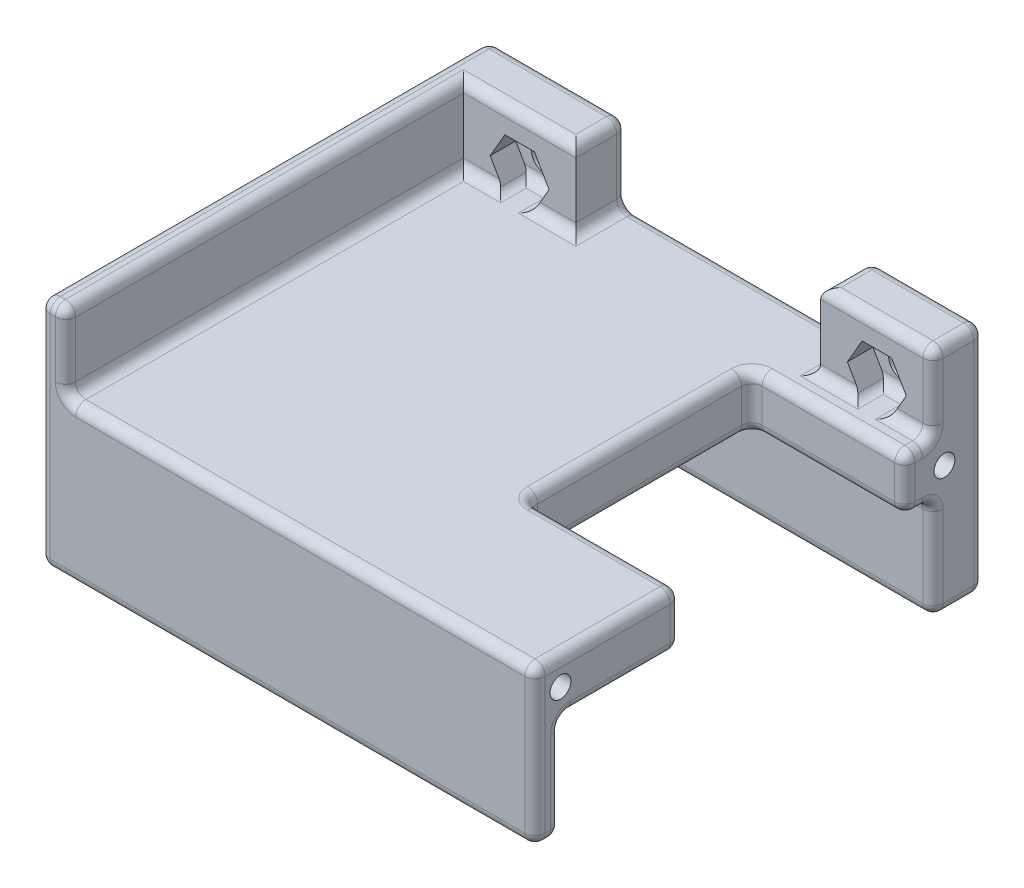
from build123d import *

# Parameters (mm, degrees)
BOSS_EXTRUDE1_DEPTH          = 5
CUT_EXTRUDE4_START           = 5
CUT_EXTRUDE4_DEPTH           = 2.5
BOSS_EXTRUDE2_DEPTH          = 41.5
BOSS_EXTRUDE3_START          = 41.5
SKETCH16_6_W                 = 46
SKETCH16_6_H                 = 10
BOSS_EXTRUDE3_DEPTH          = 2.5
SKETCH17_W                   = 15
SKETCH17_H                   = 22
CUT_EXTRUDE5_DEPTH           = 16.3
M2_5X0_45_TAPPED_HOLE2_D     = 2.05
M2_5X0_45_TAPPED_HOLE2_DEPTH = 15
M2_5X0_45_TAPPED_HOLE2_TIP   = 0.615882135
FILLET1_R                    = 1
M2_5_CLEARANCE_HOLE1_D       = 2.7


with BuildPart() as part:
    # Sketch16 → Boss-Extrude1 (new body)
    with BuildSketch(Plane.XY):
        Polygon((-12, -2.5), (-12, 5), (-25.5, 5), (-25.5, -17.8), (23, -17.8), (23, 5), (12, 5), (12, -2.5), align=None)
    extrude(amount=BOSS_EXTRUDE1_DEPTH)

    # Sketch16_5 → Cut-Extrude4 (cut)
    with BuildSketch(Plane.XY.offset(CUT_EXTRUDE4_START)):
        Polygon((-16.056624327, -2.5), (-14.613248654, 0), (-16.056624327, 2.5), (-18.943375673, 2.5), (-20.386751346, 0), (-18.943375673, -2.5), align=None)
        Polygon((18.943375673, -2.5), (20.386751346, 0), (18.943375673, 2.5), (16.056624327, 2.5), (14.613248654, 0), (16.056624327, -2.5), align=None)
    extrude(amount=-CUT_EXTRUDE4_DEPTH, mode=Mode.SUBTRACT)

    # Sketch16_4 → Boss-Extrude2 (add)
    with BuildSketch(Plane.XY):
        Polygon((-23, -7.8), (-23, -2.5), (-23, 5), (-25.5, 5), (-25.5, -17.8), (-23, -17.8), align=None)
        Polygon((-12, -2.5), (-16.056624327, -2.5), (-18.943375673, -2.5), (-23, -2.5), (-23, -7.8), (23, -7.8), (23, -2.5), (18.943375673, -2.5), (16.056624327, -2.5), (12, -2.5), align=None)
    extrude(amount=BOSS_EXTRUDE2_DEPTH)

    # Sketch16_6 → Boss-Extrude3 (add)
    with BuildSketch(Plane.XY.offset(BOSS_EXTRUDE3_START)):
        Polygon((-12, -2.5), (-16.056624327, -2.5), (-18.943375673, -2.5), (-23, -2.5), (-23, -7.8), (23, -7.8), (23, -2.5), (18.943375673, -2.5), (16.056624327, -2.5), (12, -2.5), align=None)
        Polygon((-23, -7.8), (-23, -2.5), (-23, 5), (-25.5, 5), (-25.5, -17.8), (-23, -17.8), align=None)
        with Locations((0, -12.8)):
            Rectangle(SKETCH16_6_W, SKETCH16_6_H)
    extrude(amount=BOSS_EXTRUDE3_DEPTH)

    # Sketch17 → Cut-Extrude5 (cut, through all)
    with BuildSketch(Plane(origin=(0, -2.5, 0), x_dir=(1, 0, 0), z_dir=(0, 1, 0))):
        with Locations((15.5, -18.75)):
            Rectangle(SKETCH17_W, SKETCH17_H)
    extrude(amount=-CUT_EXTRUDE5_DEPTH, mode=Mode.SUBTRACT)

    # M2.5x0.45 Tapped Hole2
    with Locations(Plane(origin=(23, 0, 0), x_dir=(0, 0, -1), z_dir=(1, 0, 0))):
        with Locations((-41.5, -5.15), (-3.875, -5.15)):
            Hole(M2_5X0_45_TAPPED_HOLE2_D / 2, depth=M2_5X0_45_TAPPED_HOLE2_DEPTH)
            with Locations((0, 0, -(M2_5X0_45_TAPPED_HOLE2_DEPTH + M2_5X0_45_TAPPED_HOLE2_TIP / 2))):  # 118° drill point
                Cone(0, M2_5X0_45_TAPPED_HOLE2_D / 2, M2_5X0_45_TAPPED_HOLE2_TIP, mode=Mode.SUBTRACT)

    # Fillet1
    fillet1_edges = [part.edges().sort_by_distance(p)[0] for p in [
        (-23, 1.25, 44),
        (-12, 1.25, 0),
        (12, 1.25, 0),
        (23, 1.25, 5),
        (23, -2.5, 36.875),
        (0, -2.5, 44),
        (-23, -2.5, 24.5),
        (-20.971687836, -2.5, 5),
        (-18.943375673, -2.5, 3.75),
        (-17.5, -2.5, 2.5),
        (-16.056624327, -2.5, 3.75),
        (-14.028312164, -2.5, 5),
        (-12, -2.5, 2.5),
        (0, -2.5, 0),
        (12, -2.5, 2.5),
        (14.028312164, -2.5, 5),
        (16.056624327, -2.5, 3.75),
        (17.5, -2.5, 2.5),
        (18.943375673, -2.5, 3.75),
        (20.971687836, -2.5, 5),
        (23, -2.5, 6.375),
        (15.5, -2.5, 7.75),
        (8, -2.5, 18.75),
        (15.5, -2.5, 29.75),
        (23, -12.8, 5),
        (23, -12.8, 41.5),
        (0, -17.8, 5),
        (0, -17.8, 41.5),
        (15.5, -7.8, 7.75),
        (23, -7.8, 6.375),
        (0, -7.8, 5),
        (0, -7.8, 41.5),
        (23, -7.8, 35.625),
        (15.5, -7.8, 29.75),
        (-23, -12.8, 41.5),
        (-23, -7.8, 23.25),
        (-23, -12.8, 5),
        (-23, -17.8, 23.25),
        (8, -7.8, 18.75),
        (8, -5.15, 29.75),
        (8, -5.15, 7.75),
        (23, 5, 2.5),
        (17.5, 5, 5),
        (12, 5, 2.5),
        (17.5, 5, 0),
        (-17.5, 5, 5),
        (-23, 5, 24.5),
        (-24.25, 5, 44),
        (-25.5, 5, 22),
        (-18.75, 5, 0),
        (-12, 5, 2.5),
        (23, -17.8, 42.75),
        (23, -17.8, 2.5),
        (23, -10.15, 44),
        (23, -5.15, 29.75),
        (-1.25, -17.8, 44),
        (-1.25, -17.8, 0),
        (-25.5, -6.4, 0),
        (-25.5, -6.4, 44),
        (23, -6.4, 0),
        (-25.5, -17.8, 22),
        (23, -5.15, 7.75),
    ]]
    fillet(fillet1_edges, radius=FILLET1_R)

    # M2.5 Clearance Hole1 (through all)
    with Locations(Plane(origin=(0, 0, 0), x_dir=(-1, 0, 0), z_dir=(0, 0, -1))):
        with Locations((-17.5, 0), (17.5, 0)):
            Hole(M2_5_CLEARANCE_HOLE1_D / 2)


solid = part.part
